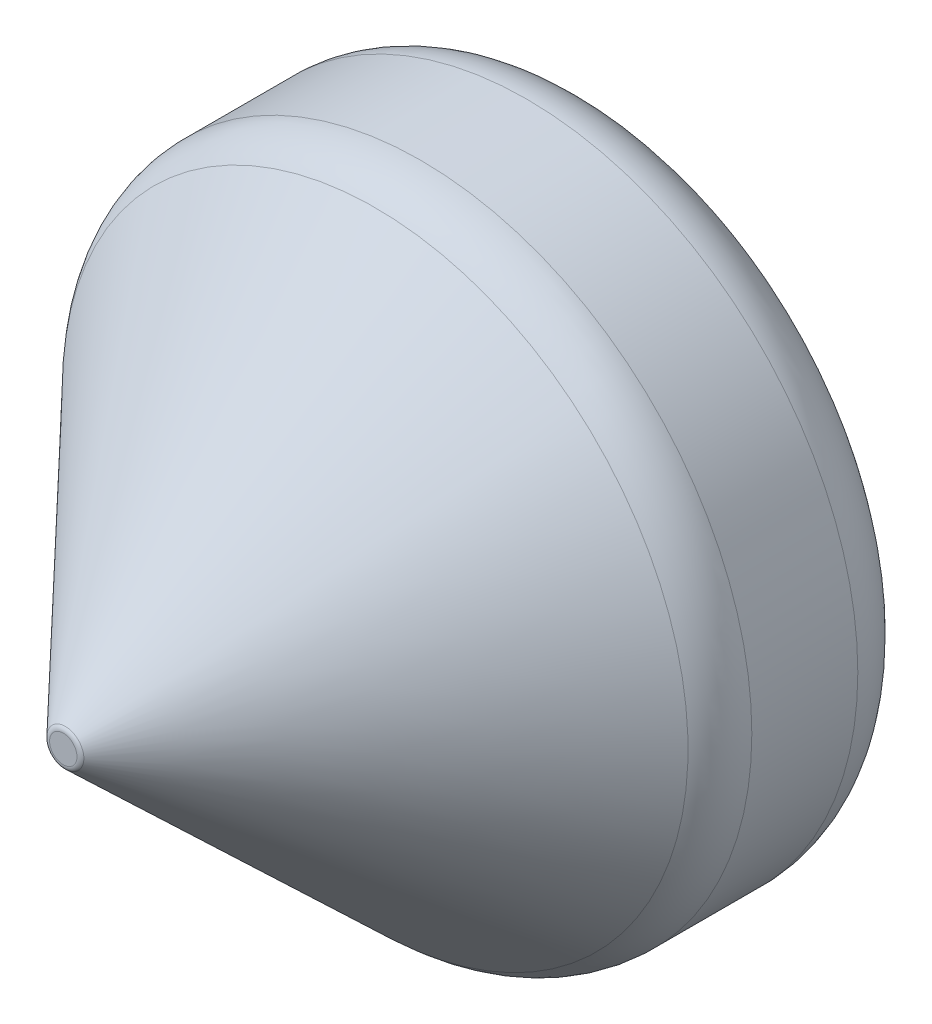
from build123d import *

# Parameters (mm, degrees)
SKETCH2_R               = 50
BOSS_EXTRUDE1_DEPTH     = 30
SKETCH4_R               = 2.5
FILLET1_R               = 10
FILLET3_R               = 1
SKETCH6_R               = 13
BOSS_EXTRUDE2_DEPTH     = 12
SKETCH7_R               = 12
CUT_EXTRUDE1_DEPTH      = 12
SKETCH8_R               = 2
CUT_EXTRUDE2_DEPTH      = 20
CUT_EXTRUDE2_DEPTH_BACK = 19
SKETCH9_W               = 12
SKETCH9_H               = 10
CUT_EXTRUDE3_DEPTH      = 17
CUT_EXTRUDE3_DEPTH_BACK = 23
FILLET4_R               = 10


with BuildPart() as part:
    # Sketch2 → Boss-Extrude1 (new body)
    with BuildSketch(Plane.XY):
        Circle(SKETCH2_R)
    extrude(amount=BOSS_EXTRUDE1_DEPTH)

    # Sketch4 → section 1 of loft2
    with BuildSketch(Plane.XY.offset(80), mode=Mode.PRIVATE) as loft2_s1:
        Circle(SKETCH4_R)
    # loft up to a face of the part (loft2)
    loft([Face(Wire([part.edges().sort_by_distance((-34.227355296, 36.448431371, 30))[0]])), loft2_s1.sketch])

    # Fillet1
    fillet1_edges = [part.edges().sort_by_distance(p)[0] for p in [
        (-50, 0, 30),
    ]]
    fillet(fillet1_edges, radius=FILLET1_R)

    # Fillet3
    fillet3_edges = [part.edges().sort_by_distance(p)[0] for p in [
        (-2.5, 0, 80),
    ]]
    fillet(fillet3_edges, radius=FILLET3_R)

    # Sketch6 → Boss-Extrude2 (add)
    with BuildSketch(Plane(origin=(0, 0, 0), x_dir=(-1, 0, 0), z_dir=(0, 0, -1))):
        Circle(SKETCH6_R)
    extrude(amount=BOSS_EXTRUDE2_DEPTH)

    # Sketch7 → Cut-Extrude1 (cut)
    with BuildSketch(Plane(origin=(0, 0, -12), x_dir=(-1, 0, 0), z_dir=(0, 0, -1))):
        Circle(SKETCH7_R)
    extrude(amount=-CUT_EXTRUDE1_DEPTH, mode=Mode.SUBTRACT)

    # Sketch8 → Cut-Extrude2 (cut, two sides)
    with BuildSketch(Plane(origin=(0, 0, 0), x_dir=(0, 0, -1), z_dir=(1, 0, 0))) as cut_extrude2_sk:
        with Locations(Location((7.94, 0, 0), (0, 0, 180))):
            Circle(SKETCH8_R)
    extrude(amount=CUT_EXTRUDE2_DEPTH, mode=Mode.SUBTRACT)
    extrude(cut_extrude2_sk.sketch, amount=-CUT_EXTRUDE2_DEPTH_BACK, mode=Mode.SUBTRACT)

    # Sketch9 → Cut-Extrude3 (cut, two sides)
    with BuildSketch(Plane(origin=(0, 0, 0), x_dir=(0, 0, -1), z_dir=(1, 0, 0))) as cut_extrude3_sk:
        with Locations((6, 8)):
            Rectangle(SKETCH9_W, SKETCH9_H)
        with Locations((6, -8)):
            Rectangle(SKETCH9_W, SKETCH9_H)
    extrude(amount=CUT_EXTRUDE3_DEPTH, mode=Mode.SUBTRACT)
    extrude(cut_extrude3_sk.sketch, amount=-CUT_EXTRUDE3_DEPTH_BACK, mode=Mode.SUBTRACT)

    # Fillet4
    fillet4_edges = [part.edges().sort_by_distance(p)[0] for p in [
        (-50, 0, 0),
    ]]
    fillet(fillet4_edges, radius=FILLET4_R)


solid = part.part
